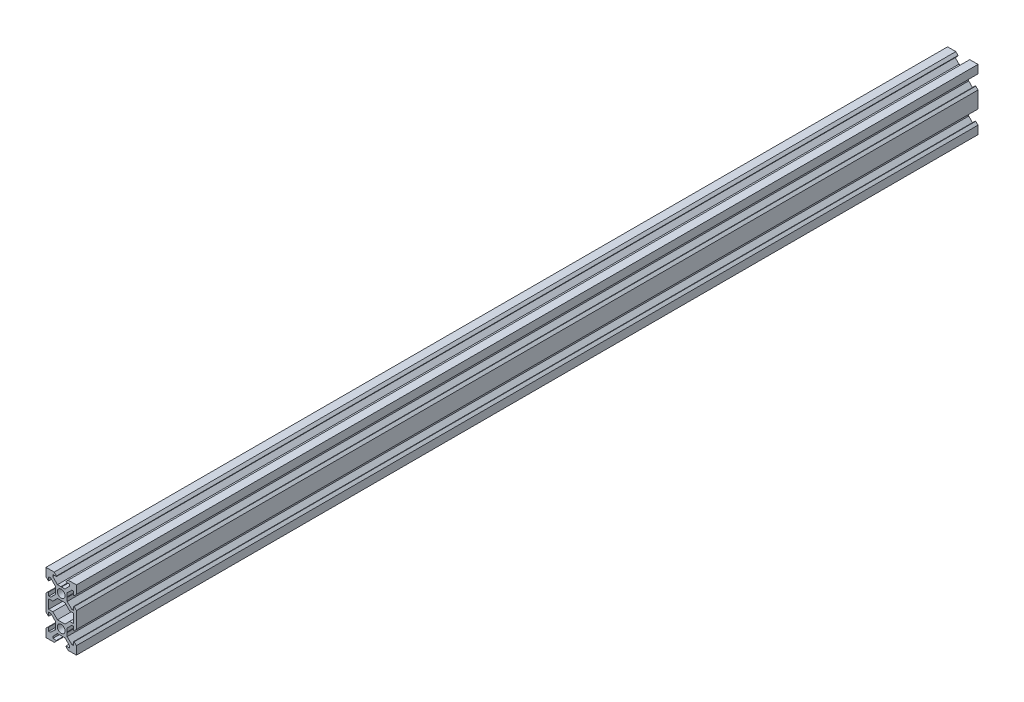
from build123d import *

# Parameters (mm, degrees)
SKETCH_1_R      = 2.55
EXTRUDE_1_DEPTH = 592.5


with BuildPart() as part:
    # Эскиз1 → Бобышка-Вытянуть1 (new body)
    with BuildSketch(Plane.XY.offset(792.9)):
        Polygon((-8.2, -3.125), (-8.506400721, -3.125), (-10, -4.58), (-10, -15.42), (-8.506400721, -16.875), (-8.2, -16.875), (-8.2, -14.5), (-7.00202244, -14.5), (-3.9, -17.521856474), (-3.9, -19.8), (-3.7, -20), (-3.9, -20.2), (-3.9, -22.478143526), (-7.00202244, -25.5), (-8.2, -25.5), (-8.2, -23.125), (-8.506400721, -23.125), (-10, -24.58), (-10, -30), (-4.58, -30), (-3.125, -28.506400721), (-3.125, -28.2), (-5.5, -28.2), (-5.5, -27.00202244), (-2.478143526, -23.9), (-0.2, -23.9), (0, -23.7), (0.2, -23.9), (2.478143526, -23.9), (5.5, -27.00202244), (5.5, -28.2), (3.125, -28.2), (3.125, -28.506400721), (4.58, -30), (10, -30), (10, -24.58), (8.506400721, -23.125), (8.2, -23.125), (8.2, -25.5), (7.00202244, -25.5), (3.9, -22.478143526), (3.9, -20.2), (3.7, -20), (3.9, -19.8), (3.9, -17.521856474), (7.00202244, -14.5), (8.2, -14.5), (8.2, -16.875), (8.506400721, -16.875), (10, -15.42), (10, -4.58), (8.506400721, -3.125), (8.2, -3.125), (8.2, -5.5), (7.00202244, -5.5), (3.9, -2.478143526), (3.9, -0.2), (3.7, 0), (3.9, 0.2), (3.9, 2.478143526), (7.00202244, 5.5), (8.2, 5.5), (8.2, 3.125), (8.506400721, 3.125), (10, 4.58), (10, 10), (4.58, 10), (3.125, 8.506400721), (3.125, 8.2), (5.5, 8.2), (5.5, 7.00202244), (2.478143526, 3.9), (0.2, 3.9), (0, 3.7), (-0.2, 3.9), (-2.478143526, 3.9), (-5.5, 7.00202244), (-5.5, 8.2), (-3.125, 8.2), (-3.125, 8.506400721), (-4.58, 10), (-10, 10), (-10, 4.58), (-8.506400721, 3.125), (-8.2, 3.125), (-8.2, 5.5), (-7.00202244, 5.5), (-3.9, 2.478143526), (-3.9, 0.2), (-3.7, 0), (-3.9, -0.2), (-3.9, -2.478143526), (-7.00202244, -5.5), (-8.2, -5.5), align=None)
        Circle(SKETCH_1_R, mode=Mode.SUBTRACT)
        with Locations((0, -20)):
            Circle(SKETCH_1_R, mode=Mode.SUBTRACT)
        Polygon((-2.478143526, -3.9), (2.478143526, -3.9), (5.5, -7.00202244), (8.2, -7.00202244), (8.2, -12.99797756), (5.5, -12.99797756), (2.478143526, -16.1), (-2.478143526, -16.1), (-5.5, -12.99797756), (-8.2, -12.99797756), (-8.2, -7.00202244), (-5.5, -7.00202244), align=None, mode=Mode.SUBTRACT)
    extrude(amount=-EXTRUDE_1_DEPTH)


solid = part.part
